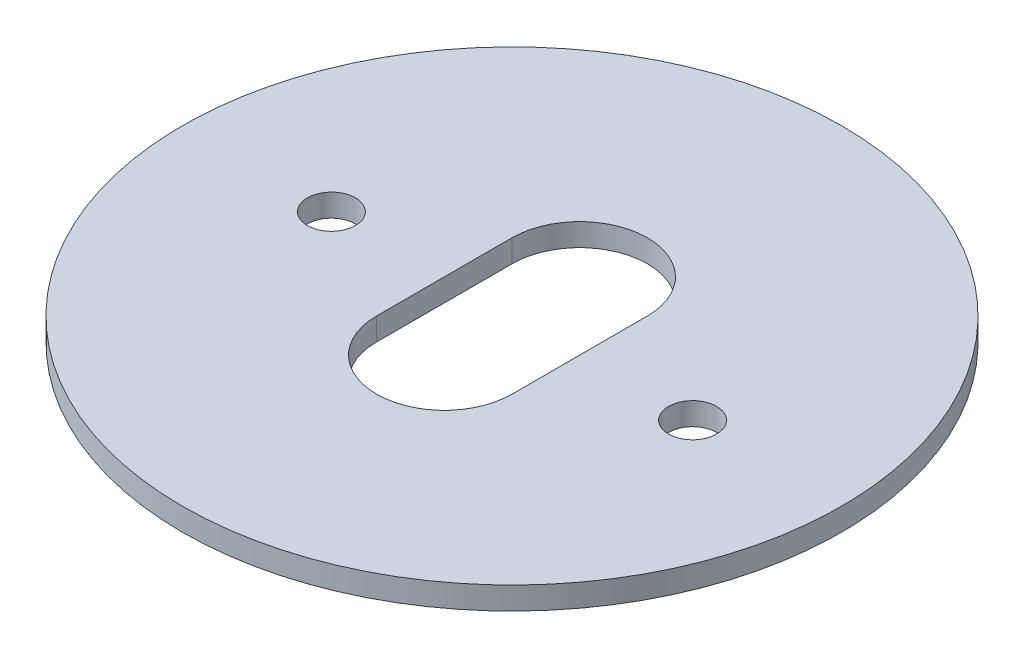
from build123d import *

# Parameters (mm, degrees)
SKETCH1_R                   = 46.355
BOSS_EXTRUDE1_DEPTH         = 1.5875
F_1_4_CLEARANCE_HOLE1_D     = 6.7564
F_1_4_CLEARANCE_HOLE1_DEPTH = 48.770172657
F_1_4_CLEARANCE_HOLE1_TIP   = 2.029827343
CUT_EXTRUDE1_DEPTH          = 4.175


with BuildPart() as part:
    # Sketch1 → Boss-Extrude1 (new body, symmetric)
    with BuildSketch(Plane(origin=(0, 0, 0), x_dir=(1, 0, 0), z_dir=(0, 1, 0))):
        Circle(SKETCH1_R)
    extrude(amount=BOSS_EXTRUDE1_DEPTH, both=True)

    # 1/4 Clearance Hole1
    with Locations(Plane(origin=(0, 1.5875, 0), x_dir=(1, 0, 0), z_dir=(0, 1, 0))):
        with Locations((25.4, 0), (-25.4, 0)):
            Hole(F_1_4_CLEARANCE_HOLE1_D / 2, depth=F_1_4_CLEARANCE_HOLE1_DEPTH)
            with Locations((0, 0, -(F_1_4_CLEARANCE_HOLE1_DEPTH + F_1_4_CLEARANCE_HOLE1_TIP / 2))):  # 118° drill point
                Cone(0, F_1_4_CLEARANCE_HOLE1_D / 2, F_1_4_CLEARANCE_HOLE1_TIP, mode=Mode.SUBTRACT)

    # Sketch4 → Cut-Extrude1 (cut, through all)
    with BuildSketch(Plane(origin=(0, 1.5875, 0), x_dir=(1, 0, 0), z_dir=(0, 1, 0))):
        with BuildLine():
            Line((9.525, 9.525), (9.525, -9.525))
            ThreePointArc((9.525, -9.525), (0, -19.05), (-9.525, -9.525))
            Line((-9.525, -9.525), (-9.525, 9.525))
            ThreePointArc((-9.525, 9.525), (0, 19.05), (9.525, 9.525))
        make_face()
    extrude(amount=-CUT_EXTRUDE1_DEPTH, mode=Mode.SUBTRACT)


solid = part.part
